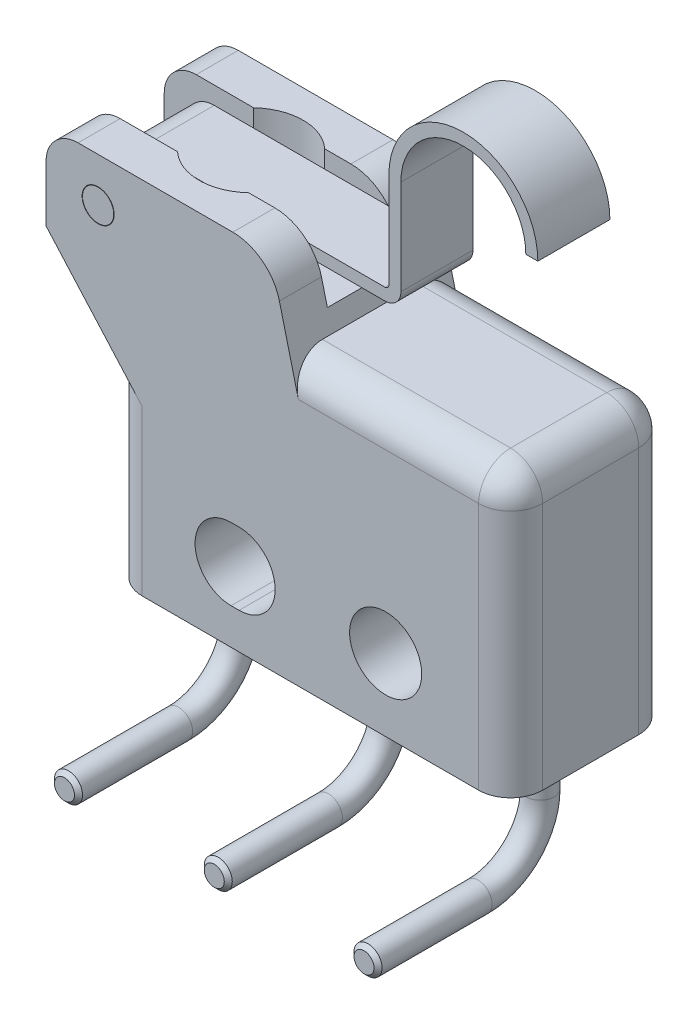
from build123d import *

# Parameters (mm, degrees)
BOSS_EXTRUDE3_DEPTH        = 5.08
SKETCH5_R                  = 1.143
SKETCH5_R_2                = 0.508
CUT_EXTRUDE1_DEPTH         = 6.08
CUT_EXTRUDE2_DEPTH         = 1.905
SKETCH7_W                  = 2.032
SKETCH7_H                  = 2.413
CUT_EXTRUDE3_DEPTH         = 10.525
SKETCH8_R                  = 0.4953
BOSS_EXTRUDE4_DEPTH        = 5.08
SKETCH9_R                  = 1.5875
BOSS_EXTRUDE5_DEPTH        = 0.254
SKETCH10_R                 = 0.7874
BOSS_EXTRUDE6_DEPTH        = 0.7112
BOSS_EXTRUDE7_DEPTH        = 2.286
SKETCH13_R                 = 0.4445
CHAMFER1_SIZE              = 0.127
LPATTERN1_COUNT            = 2
LPATTERN1_PITCH            = 4.7498
LPATTERN1_COUNT_DIR2       = 2
LPATTERN1_PITCH_DIR2       = 4.7498
CHAMFER1_OF_LPATTERN1_SIZE = 0.127
FILLET1_R                  = 1.016
FILLET2_R                  = 1.524
CUT_EXTRUDE4_DEPTH         = 0.0254
CUT_EXTRUDE5_DEPTH         = 0.0254
CUT_EXTRUDE6_DEPTH         = 0.0254


with BuildPart() as part:
    # Sketch4 → Boss-Extrude3 (new body)
    with BuildSketch(Plane.XY):
        Polygon((0, 0), (12.7, 0), (12.7, 8.89), (5.715, 8.89), (5.08, 11.43), (-2.032, 11.43), (-2.032, 8.636), (0, 6.35), align=None)
    extrude(amount=BOSS_EXTRUDE3_DEPTH)

    # Sketch5 → Cut-Extrude1 (cut, through all)
    with BuildSketch(Plane.XY.offset(5.08)):
        with Locations((8.7376, 2.286)):
            Circle(SKETCH5_R)
        with Locations((-0.381, 10.033)):
            Circle(SKETCH5_R_2)
        with BuildLine():
            Line((3.8354, 3.429), (4.0894, 3.429))
            ThreePointArc((4.0894, 3.429), (5.2324, 2.286), (4.0894, 1.143))
            Line((4.0894, 1.143), (3.8354, 1.143))
            ThreePointArc((3.8354, 1.143), (2.6924, 2.286), (3.8354, 3.429))
        make_face()
    extrude(amount=-CUT_EXTRUDE1_DEPTH, mode=Mode.SUBTRACT)

    # Sketch6 → Cut-Extrude2 (cut)
    with BuildSketch(Plane(origin=(0, 11.43, 0), x_dir=(1, 0, 0), z_dir=(0, 1, 0))):
        with BuildLine():
            Line((-2.032, -1.3335), (0.803386801, -1.3335))
            ThreePointArc((0.803386801, -1.3335), (1.9304, -0.889), (3.057413199, -1.3335))
            Line((3.057413199, -1.3335), (5.842, -1.3335))
            Line((5.842, -1.3335), (5.842, -3.7465))
            Line((5.842, -3.7465), (3.057413199, -3.7465))
            ThreePointArc((3.057413199, -3.7465), (1.9304, -4.191), (0.803386801, -3.7465))
            Line((0.803386801, -3.7465), (-2.032, -3.7465))
            Line((-2.032, -3.7465), (-2.032, -1.3335))
        make_face()
    extrude(amount=-CUT_EXTRUDE2_DEPTH, mode=Mode.SUBTRACT)

    # Sketch7 → Cut-Extrude3 (cut, through all)
    with BuildSketch(Plane(origin=(0, 9.525, 0), x_dir=(1, 0, 0), z_dir=(0, 1, 0))):
        with Locations((-1.016, -2.54)):
            Rectangle(SKETCH7_W, SKETCH7_H)
    extrude(amount=-CUT_EXTRUDE3_DEPTH, mode=Mode.SUBTRACT)

    # Sketch9 → Boss-Extrude5 (add)
    with BuildSketch(Plane(origin=(0, 9.525, 0), x_dir=(1, 0, 0), z_dir=(0, 1, 0))):
        with Locations((1.9304, -2.54)):
            Circle(SKETCH9_R)
    extrude(amount=BOSS_EXTRUDE5_DEPTH)

    # Sketch10 → Boss-Extrude6 (add)
    with BuildSketch(Plane(origin=(0, 9.779, 0), x_dir=(1, 0, 0), z_dir=(0, 1, 0))):
        with Locations((1.9304, -2.54)):
            Circle(SKETCH10_R)
    extrude(amount=BOSS_EXTRUDE6_DEPTH)

    # Sweep1: sweep along a path in Sketch15
    with BuildLine(Plane(origin=(6.35, 0, 0), x_dir=(0, 0, -1), z_dir=(1, 0, 0))) as sweep1_path:
        Line((-2.54, 0), (-2.54, -1.524))
        ThreePointArc((-2.54, -1.524), (-3.116560301, -2.915939699), (-4.5085, -3.4925))
        Line((-4.5085, -3.4925), (-8.128, -3.4925))
    # Sketch13 → Sweep1 (sweep)
    with BuildSketch(Plane.XZ):
        with Locations((6.35, 2.54)):
            Circle(SKETCH13_R)
    sweep1 = sweep(path=sweep1_path.line)

    # Chamfer1
    chamfer1_edges = [part.edges().sort_by_distance(p)[0] for p in [
        (5.9055, -3.4925, 8.128),
    ]]
    chamfer(chamfer1_edges, length=CHAMFER1_SIZE)

    # LPattern1: Sweep1 2 × 2
    with Locations(*[Vector(1, 0, 0) * (i * LPATTERN1_PITCH) + Vector(-1, 0, 0) * (j * LPATTERN1_PITCH_DIR2) for i in range(LPATTERN1_COUNT) for j in range(LPATTERN1_COUNT_DIR2) if (i, j) != (0, 0)]):
        add(sweep1)

    # Chamfer1 of LPattern1
    chamfer1_of_lpattern1_edges = [part.edges().sort_by_distance(p)[0] for p in [
        (1.1557, -3.4925, 8.128),
        (10.6553, -3.4925, 8.128),
        (5.9055, -3.4925, 8.128),
    ]]
    chamfer(chamfer1_of_lpattern1_edges, length=CHAMFER1_OF_LPATTERN1_SIZE)

    # Fillet1
    fillet1_edges = [part.edges().sort_by_distance(p)[0] for p in [
        (12.7, 4.445, 5.08),
        (0, 3.175, 0),
        (9.2075, 8.89, 5.08),
        (-2.032, 11.43, 4.41325),
        (12.7, 8.89, 2.54),
        (0, 3.175, 5.08),
        (-2.032, 11.43, 0.66675),
        (9.2075, 8.89, 0),
        (12.7, 4.445, 0),
    ]]
    fillet(fillet1_edges, radius=FILLET1_R)

    # Fillet2
    fillet2_edges = [part.edges().sort_by_distance(p)[0] for p in [
        (5.08, 11.43, 4.41325),
        (5.08, 11.43, 0.66675),
    ]]
    fillet(fillet2_edges, radius=FILLET2_R)

    # Sketch16 → Cut-Extrude4 (cut)
    with BuildSketch(Plane.XZ):
        with BuildLine():
            Line((1.939123423, 1.681786727), (2.018625627, 1.577903847))
            add(Edge.make_bspline(
                [(2.018625627, 1.577903847), (2.009793963, 1.570493212), (1.992249706, 1.555771854), (1.967611674, 1.532089284), (1.94453688, 1.507402641), (1.922877068, 1.481746274), (1.903502788, 1.454526435), (1.884905157, 1.426780277), (1.868622291, 1.397499658), (1.848730733, 1.357215763), (1.828426479, 1.304312077), (1.810963067, 1.237945187), (1.799951042, 1.168569238), (1.798750274, 1.121249335), (1.798139516, 1.097180523)],
                knots=[0, 0, 0, 0, 3.4579e-05, 6.8692e-05, 0.000102441, 0.00013593, 0.000169326, 0.000202622, 0.000236084, 0.000269743, 0.000337363, 0.000405629, 0.000475341, 0.000547505, 0.000547505, 0.000547505, 0.000547505], degree=3))
            add(Edge.make_bspline(
                [(1.798139516, 1.097180523), (1.798292204, 1.083919872), (1.798596163, 1.057521639), (1.80260616, 1.018344984), (1.808242242, 0.979899872), (1.816605088, 0.942211312), (1.827178071, 0.905327277), (1.839812083, 0.869006639), (1.855443223, 0.833775245), (1.872719875, 0.799145756), (1.892233756, 0.765967218), (1.913519093, 0.734574698), (1.936336334, 0.705080853), (1.960775997, 0.677469078), (1.986709644, 0.651686381), (2.014427817, 0.628057197), (2.0436342, 0.606265825), (2.074353049, 0.586436456), (2.106298263, 0.568585419), (2.139652232, 0.553575473), (2.173843867, 0.540465888), (2.209115563, 0.529929183), (2.245232887, 0.521653986), (2.282345462, 0.515932896), (2.320382924, 0.511969372), (2.346164376, 0.511666806), (2.359160065, 0.511514291)],
                knots=[0, 0, 0, 0, 3.9765e-05, 7.9161e-05, 0.000118027, 0.000156286, 0.000194871, 0.000233091, 0.000271543, 0.000310416, 0.00034914, 0.00038692, 0.000424131, 0.000460928, 0.00049747, 0.000533745, 0.000570104, 0.00060671, 0.000643364, 0.000679771, 0.00071634, 0.000753146, 0.000790111, 0.000827406, 0.000865747, 0.000904717, 0.000904717, 0.000904717, 0.000904717], degree=3))
            add(Edge.make_bspline(
                [(2.359160065, 0.511514291), (2.378712836, 0.511992347), (2.417102109, 0.512930946), (2.473340046, 0.521248816), (2.527267745, 0.533990163), (2.578520068, 0.552773327), (2.627524265, 0.576396137), (2.673686059, 0.605870889), (2.717681735, 0.640137018), (2.758445743, 0.679546049), (2.795681059, 0.722789867), (2.828470853, 0.769185352), (2.85580412, 0.818618779), (2.878549205, 0.870543853), (2.896033144, 0.925360277), (2.908341608, 0.982969442), (2.916370646, 1.04324606), (2.917139332, 1.084433898), (2.917530541, 1.105395751)],
                knots=[0, 0, 0, 0, 5.8627e-05, 0.000115105, 0.000170189, 0.000224596, 0.000278524, 0.000333076, 0.00038858, 0.000445557, 0.000502873, 0.000559559, 0.000615671, 0.000672044, 0.000729369, 0.00078795, 0.000848595, 0.000911447, 0.000911447, 0.000911447, 0.000911447], degree=3))
            add(Edge.make_bspline(
                [(2.917530541, 1.105395751), (2.916892223, 1.128491113), (2.915635859, 1.173948309), (2.904992333, 1.240611224), (2.887734728, 1.304427123), (2.863582834, 1.36539944), (2.832186133, 1.423356286), (2.794124733, 1.478388357), (2.749036584, 1.530542105), (2.71460933, 1.561903274), (2.69704443, 1.577903847)],
                knots=[0, 0, 0, 0, 6.9253e-05, 0.000136306, 0.000201943, 0.000267246, 0.000332579, 0.000399252, 0.000467635, 0.000538868, 0.000538868, 0.000538868, 0.000538868], degree=3))
            Line((2.69704443, 1.577903847), (2.775751612, 1.681786727))
            add(Edge.make_bspline(
                [(2.775751612, 1.681786727), (2.786538094, 1.673426315), (2.808059391, 1.656745536), (2.838405723, 1.629740455), (2.866923767, 1.601271188), (2.893471107, 1.571264557), (2.918157625, 1.539667673), (2.940996731, 1.506483437), (2.961867219, 1.471740175), (2.981037786, 1.435713847), (2.997916821, 1.398321438), (3.012874111, 1.359892131), (3.025257096, 1.320190298), (3.035731711, 1.279550142), (3.043200583, 1.237604624), (3.049148207, 1.194841329), (3.052676779, 1.150860009), (3.05303352, 1.121214092), (3.053214302, 1.106190773)],
                knots=[0, 0, 0, 0, 4.0932e-05, 8.1668e-05, 0.00012177, 0.000161758, 0.000201782, 0.00024199, 0.00028253, 0.000323311, 0.000364346, 0.000405538, 0.000446942, 0.000489041, 0.000531351, 0.000574677, 0.000618538, 0.000663602, 0.000663602, 0.000663602, 0.000663602], degree=3))
            add(Edge.make_bspline(
                [(3.053214302, 1.106190773), (3.053115275, 1.091962363), (3.052919461, 1.063827445), (3.049747422, 1.022288333), (3.045419694, 0.981848819), (3.038903335, 0.942624481), (3.031213659, 0.90440127), (3.020905773, 0.867525692), (3.009358916, 0.831634884), (2.995787685, 0.796873041), (2.980473533, 0.763210595), (2.963165414, 0.730756118), (2.944008876, 0.699524538), (2.923426179, 0.669208799), (2.900756186, 0.640256736), (2.876313738, 0.612417457), (2.850181216, 0.585534854), (2.831337269, 0.568902887), (2.82186289, 0.56054065)],
                knots=[0, 0, 0, 0, 4.2674e-05, 8.4382e-05, 0.000124914, 0.000164647, 0.000203628, 0.000241816, 0.000279444, 0.000316698, 0.000353697, 0.000390331, 0.000426963, 0.000463569, 0.000500199, 0.000537195, 0.000574675, 0.000612574, 0.000612574, 0.000612574, 0.000612574], degree=3))
            add(Edge.make_bspline(
                [(2.82186289, 0.56054065), (2.805405017, 0.547147694), (2.772687967, 0.520523473), (2.719668205, 0.486445248), (2.664360374, 0.457371731), (2.606444123, 0.433602313), (2.545896936, 0.415344628), (2.482816215, 0.402508288), (2.417328063, 0.394225018), (2.372789191, 0.393274271), (2.350149815, 0.392791)],
                knots=[0, 0, 0, 0, 6.3616e-05, 0.000126463, 0.000188695, 0.00025085, 0.000313978, 0.000378113, 0.000443788, 0.000511682, 0.000511682, 0.000511682, 0.000511682], degree=3))
            add(Edge.make_bspline(
                [(2.350149815, 0.392791), (2.326354153, 0.393378826), (2.279537672, 0.394535338), (2.210831446, 0.404361129), (2.145006364, 0.420167639), (2.082185306, 0.442618248), (2.022037848, 0.471081878), (1.965023464, 0.506243723), (1.910777531, 0.547695292), (1.860123146, 0.595111486), (1.813806188, 0.647108663), (1.77305801, 0.702791667), (1.739146925, 0.76205151), (1.710800162, 0.824235341), (1.689011927, 0.889808798), (1.673759383, 0.958631976), (1.664265711, 1.030575554), (1.663065558, 1.079660459), (1.662455755, 1.104600729)],
                knots=[0, 0, 0, 0, 7.1358e-05, 0.000140392, 0.000207753, 0.000274138, 0.000340163, 0.000407022, 0.000474707, 0.000544645, 0.00061485, 0.000683335, 0.000751245, 0.000819323, 0.000888041, 0.000958119, 0.001030533, 0.001105332, 0.001105332, 0.001105332, 0.001105332], degree=3))
            add(Edge.make_bspline(
                [(1.662455755, 1.104600729), (1.66263815, 1.119800792), (1.662999183, 1.149887786), (1.666514386, 1.194396208), (1.672386606, 1.237725621), (1.680337206, 1.279921595), (1.690349382, 1.321106122), (1.702827761, 1.361202151), (1.717684148, 1.400111499), (1.734649453, 1.437821524), (1.753726842, 1.474077664), (1.77469129, 1.508857156), (1.797436871, 1.542021346), (1.822196447, 1.573397858), (1.848764641, 1.603025083), (1.876830243, 1.631342512), (1.907113438, 1.657525853), (1.928433896, 1.673684965), (1.939123423, 1.681786727)],
                knots=[0, 0, 0, 0, 4.5594e-05, 9.0248e-05, 0.000133836, 0.000176715, 0.000219008, 0.000260918, 0.000302605, 0.000343881, 0.000384896, 0.000425436, 0.000465645, 0.00050546, 0.00054525, 0.000584976, 0.000624989, 0.000665222, 0.000665222, 0.000665222, 0.000665222], degree=3))
        make_face()
    extrude(amount=-CUT_EXTRUDE4_DEPTH, mode=Mode.SUBTRACT)

    # Sketch17 → Cut-Extrude5 (cut)
    with BuildSketch(Plane.XZ):
        Polygon((10.765601094, 0.569944606), (9.442684428, 0.569944606), (9.442684428, 0.594855296), (10.483898287, 1.46884952), (9.442684428, 1.46884952), (9.442684428, 1.587572811), (10.765601094, 1.587572811), (10.765601094, 1.560542062), (9.726772302, 0.688667897), (10.765601094, 0.688667897), align=None)
        with BuildLine():
            Line((11.042268763, 1.791098452), (11.121770966, 1.687215573))
            add(Edge.make_bspline(
                [(11.121770966, 1.687215573), (11.112939303, 1.679804938), (11.095395046, 1.665083579), (11.070757013, 1.641401009), (11.04768222, 1.616714366), (11.026022407, 1.591057999), (11.006648128, 1.56383816), (10.988050496, 1.536092002), (10.97176763, 1.506811383), (10.951876072, 1.466527489), (10.931571818, 1.413623802), (10.914108407, 1.347256913), (10.903096381, 1.277880964), (10.901895614, 1.230561061), (10.901284855, 1.206492249)],
                knots=[0, 0, 0, 0, 3.4579e-05, 6.8692e-05, 0.000102441, 0.00013593, 0.000169326, 0.000202622, 0.000236084, 0.000269743, 0.000337363, 0.000405629, 0.000475341, 0.000547505, 0.000547505, 0.000547505, 0.000547505], degree=3))
            add(Edge.make_bspline(
                [(10.901284855, 1.206492249), (10.901437543, 1.193231597), (10.901741503, 1.166833365), (10.905751499, 1.12765671), (10.911387582, 1.089211598), (10.919750427, 1.051523038), (10.930323411, 1.014639003), (10.942957423, 0.978318364), (10.958588563, 0.943086971), (10.975865214, 0.908457481), (10.995379095, 0.875278944), (11.016664432, 0.843886423), (11.039481673, 0.814392578), (11.063921336, 0.786780804), (11.089854983, 0.760998106), (11.117573156, 0.737368923), (11.14677954, 0.71557755), (11.177498388, 0.695748182), (11.209443603, 0.677897145), (11.242797571, 0.662887199), (11.276989206, 0.649777613), (11.312260903, 0.639240908), (11.348378226, 0.630965711), (11.385490801, 0.625244621), (11.423528264, 0.621281097), (11.449309715, 0.620978531), (11.462305405, 0.620826016)],
                knots=[0, 0, 0, 0, 3.9765e-05, 7.9161e-05, 0.000118027, 0.000156286, 0.000194871, 0.000233091, 0.000271543, 0.000310416, 0.00034914, 0.00038692, 0.000424131, 0.000460928, 0.00049747, 0.000533745, 0.000570104, 0.00060671, 0.000643364, 0.000679771, 0.00071634, 0.000753146, 0.000790111, 0.000827406, 0.000865747, 0.000904717, 0.000904717, 0.000904717, 0.000904717], degree=3))
            add(Edge.make_bspline(
                [(11.462305405, 0.620826016), (11.481858176, 0.621304072), (11.520247449, 0.622242671), (11.576485385, 0.630560541), (11.630413085, 0.643301888), (11.681665408, 0.662085053), (11.730669604, 0.685707862), (11.776831399, 0.715182614), (11.820827075, 0.749448743), (11.861591082, 0.788857775), (11.898826398, 0.832101593), (11.931616192, 0.878497078), (11.958949459, 0.927930505), (11.981694544, 0.979855579), (11.999178483, 1.034672002), (12.011486947, 1.092281167), (12.019515985, 1.152557785), (12.020284671, 1.193745624), (12.020675881, 1.214707477)],
                knots=[0, 0, 0, 0, 5.8627e-05, 0.000115105, 0.000170189, 0.000224596, 0.000278524, 0.000333076, 0.00038858, 0.000445557, 0.000502873, 0.000559559, 0.000615671, 0.000672044, 0.000729369, 0.00078795, 0.000848595, 0.000911447, 0.000911447, 0.000911447, 0.000911447], degree=3))
            add(Edge.make_bspline(
                [(12.020675881, 1.214707477), (12.020037562, 1.237802838), (12.018781199, 1.283260035), (12.008137673, 1.349922949), (11.990880067, 1.413738849), (11.966728174, 1.474711166), (11.935331473, 1.532668011), (11.897270073, 1.587700082), (11.852181923, 1.639853831), (11.817754669, 1.671215), (11.80018977, 1.687215573)],
                knots=[0, 0, 0, 0, 6.9253e-05, 0.000136306, 0.000201943, 0.000267246, 0.000332579, 0.000399252, 0.000467635, 0.000538868, 0.000538868, 0.000538868, 0.000538868], degree=3))
            Line((11.80018977, 1.687215573), (11.878896951, 1.791098452))
            add(Edge.make_bspline(
                [(11.878896951, 1.791098452), (11.889683433, 1.78273804), (11.911204731, 1.766057262), (11.941551062, 1.73905218), (11.970069107, 1.710582913), (11.996616446, 1.680576282), (12.021302964, 1.648979399), (12.04414207, 1.615795163), (12.065012558, 1.5810519), (12.084183125, 1.545025572), (12.10106216, 1.507633164), (12.116019451, 1.469203856), (12.128402435, 1.429502023), (12.13887705, 1.388861867), (12.146345922, 1.346916349), (12.152293547, 1.304153054), (12.155822118, 1.260171734), (12.15617886, 1.230525818), (12.156359641, 1.215502499)],
                knots=[0, 0, 0, 0, 4.0932e-05, 8.1668e-05, 0.00012177, 0.000161758, 0.000201782, 0.00024199, 0.00028253, 0.000323311, 0.000364346, 0.000405538, 0.000446942, 0.000489041, 0.000531351, 0.000574677, 0.000618538, 0.000663602, 0.000663602, 0.000663602, 0.000663602], degree=3))
            add(Edge.make_bspline(
                [(12.156359641, 1.215502499), (12.156260614, 1.201274089), (12.156064801, 1.17313917), (12.152892761, 1.131600059), (12.148565034, 1.091160544), (12.142048674, 1.051936207), (12.134358998, 1.013712996), (12.124051113, 0.976837418), (12.112504255, 0.940946609), (12.098933025, 0.906184766), (12.083618873, 0.87252232), (12.066310754, 0.840067844), (12.047154215, 0.808836264), (12.026571518, 0.778520524), (12.003901526, 0.749568461), (11.979459078, 0.721729182), (11.953326556, 0.69484658), (11.934482608, 0.678214613), (11.925008229, 0.669852375)],
                knots=[0, 0, 0, 0, 4.2674e-05, 8.4382e-05, 0.000124914, 0.000164647, 0.000203628, 0.000241816, 0.000279444, 0.000316698, 0.000353697, 0.000390331, 0.000426963, 0.000463569, 0.000500199, 0.000537195, 0.000574675, 0.000612574, 0.000612574, 0.000612574, 0.000612574], degree=3))
            add(Edge.make_bspline(
                [(11.925008229, 0.669852375), (11.908550357, 0.656459419), (11.875833306, 0.629835199), (11.822813544, 0.595756974), (11.767505714, 0.566683456), (11.709589462, 0.542914039), (11.649042275, 0.524656353), (11.585961555, 0.511820013), (11.520473403, 0.503536743), (11.47593453, 0.502585996), (11.453295155, 0.502102726)],
                knots=[0, 0, 0, 0, 6.3616e-05, 0.000126463, 0.000188695, 0.00025085, 0.000313978, 0.000378113, 0.000443788, 0.000511682, 0.000511682, 0.000511682, 0.000511682], degree=3))
            add(Edge.make_bspline(
                [(11.453295155, 0.502102726), (11.429499492, 0.502690552), (11.382683012, 0.503847063), (11.313976786, 0.513672855), (11.248151703, 0.529479364), (11.185330645, 0.551929974), (11.125183188, 0.580393603), (11.068168804, 0.615555449), (11.013922871, 0.657007017), (10.963268486, 0.704423211), (10.916951528, 0.756420388), (10.87620335, 0.812103392), (10.842292265, 0.871363235), (10.813945501, 0.933547066), (10.792157266, 0.999120523), (10.776904723, 1.067943701), (10.767411051, 1.139887279), (10.766210898, 1.188972184), (10.765601094, 1.213912454)],
                knots=[0, 0, 0, 0, 7.1358e-05, 0.000140392, 0.000207753, 0.000274138, 0.000340163, 0.000407022, 0.000474707, 0.000544645, 0.00061485, 0.000683335, 0.000751245, 0.000819323, 0.000888041, 0.000958119, 0.001030533, 0.001105332, 0.001105332, 0.001105332, 0.001105332], degree=3))
            add(Edge.make_bspline(
                [(10.765601094, 1.213912454), (10.76578349, 1.229112518), (10.766144523, 1.259199512), (10.769659726, 1.303707933), (10.775531945, 1.347037346), (10.783482545, 1.38923332), (10.793494721, 1.430417847), (10.8059731, 1.470513877), (10.820829487, 1.509423224), (10.837794792, 1.54713325), (10.856872181, 1.583389389), (10.87783663, 1.618168882), (10.900582211, 1.651333071), (10.925341787, 1.682709584), (10.951909981, 1.712336808), (10.979975583, 1.740654238), (11.010258778, 1.766837578), (11.031579236, 1.78299669), (11.042268763, 1.791098452)],
                knots=[0, 0, 0, 0, 4.5594e-05, 9.0248e-05, 0.000133836, 0.000176715, 0.000219008, 0.000260918, 0.000302605, 0.000343881, 0.000384896, 0.000425436, 0.000465645, 0.00050546, 0.00054525, 0.000584976, 0.000624989, 0.000665222, 0.000665222, 0.000665222, 0.000665222], degree=3))
        make_face()
    extrude(amount=-CUT_EXTRUDE5_DEPTH, mode=Mode.SUBTRACT)

    # Sketch18 → Cut-Extrude6 (cut)
    with BuildSketch(Plane.XZ):
        Polygon((6.318402977, 0.619854477), (4.99548631, 0.619854477), (4.99548631, 0.644765168), (6.036700169, 1.518759392), (4.99548631, 1.518759392), (4.99548631, 1.637482682), (6.318402977, 1.637482682), (6.318402977, 1.610451933), (5.279574184, 0.738577768), (6.318402977, 0.738577768), align=None)
        with BuildLine():
            add(Edge.make_bspline(
                [(6.318402977, 1.238911635), (6.319012972, 1.263410227), (6.320211053, 1.311527483), (6.329684946, 1.382179367), (6.345277982, 1.449831715), (6.367298678, 1.514523418), (6.395845743, 1.576008438), (6.430522252, 1.634460425), (6.471538941, 1.689704204), (6.518293518, 1.741359509), (6.569497411, 1.788481115), (6.624312149, 1.829830569), (6.682048567, 1.864712735), (6.742709676, 1.893267587), (6.806153848, 1.915685039), (6.872736658, 1.931150375), (6.942022006, 1.941030271), (6.989279214, 1.942185241), (7.013252236, 1.942771144)],
                knots=[0, 0, 0, 0, 7.3476e-05, 0.000144313, 0.000213417, 0.000281466, 0.000348931, 0.000416423, 0.000485008, 0.000554995, 0.000625142, 0.000693461, 0.000760634, 0.000827139, 0.000894273, 0.000962087, 0.001031909, 0.001103797, 0.001103797, 0.001103797, 0.001103797], degree=3))
            add(Edge.make_bspline(
                [(7.013252236, 1.942771144), (7.037048528, 1.942185044), (7.083953777, 1.941029773), (7.152801431, 1.931142359), (7.218975052, 1.915616032), (7.282327149, 1.893545146), (7.342865053, 1.864968382), (7.400645179, 1.830034864), (7.455606327, 1.788763887), (7.507162973, 1.741842383), (7.554325367, 1.690540947), (7.595924435, 1.635936877), (7.630821786, 1.578201999), (7.659695427, 1.517934616), (7.681645703, 1.454661489), (7.697626228, 1.388843058), (7.707408044, 1.320120723), (7.708570617, 1.273306463), (7.709161524, 1.249511929)],
                knots=[0, 0, 0, 0, 7.1358e-05, 0.000140655, 0.000208211, 0.000275008, 0.000341513, 0.000408685, 0.000477216, 0.000547381, 0.000617528, 0.000686007, 0.000752953, 0.000819571, 0.000886118, 0.000953478, 0.001022513, 0.001093871, 0.001093871, 0.001093871, 0.001093871], degree=3))
            add(Edge.make_bspline(
                [(7.709161524, 1.249511929), (7.708575893, 1.225539047), (7.707421457, 1.178282114), (7.69752551, 1.108909484), (7.682050672, 1.042280694), (7.659935498, 0.978586282), (7.631353985, 0.917790728), (7.596502925, 0.859775131), (7.555149631, 0.804772358), (7.508217622, 0.753238424), (7.457125994, 0.706086198), (7.402382094, 0.664977743), (7.345059942, 0.630118846), (7.285000461, 0.601633301), (7.222493993, 0.579081556), (7.157123586, 0.563696104), (7.089261928, 0.553741741), (7.043057023, 0.552594641), (7.019612412, 0.552012597)],
                knots=[0, 0, 0, 0, 7.1887e-05, 0.000141709, 0.000209781, 0.000276828, 0.000343573, 0.000410973, 0.000479504, 0.000549668, 0.000619816, 0.000687763, 0.00075471, 0.000820735, 0.000886871, 0.000953654, 0.001021901, 0.0010922, 0.0010922, 0.0010922, 0.0010922], degree=3))
            add(Edge.make_bspline(
                [(7.019612412, 0.552012597), (7.003876254, 0.552214676), (6.972602458, 0.552616286), (6.926161808, 0.557451241), (6.880468018, 0.564467122), (6.835651023, 0.574522012), (6.791820532, 0.587672434), (6.748674261, 0.603189123), (6.706649461, 0.62214079), (6.665547048, 0.643564726), (6.62600775, 0.667476183), (6.588633622, 0.693887552), (6.553111043, 0.721871159), (6.520360538, 0.752548989), (6.489429365, 0.784909967), (6.460792861, 0.819479056), (6.434192806, 0.856045321), (6.410221427, 0.894766102), (6.38854104, 0.934687295), (6.369936352, 0.975840125), (6.353968346, 1.017665674), (6.34102613, 1.060359842), (6.330808664, 1.103809253), (6.323851122, 1.148108737), (6.319003835, 1.193223002), (6.318604125, 1.223616566), (6.318402977, 1.238911635)],
                knots=[0, 0, 0, 0, 4.719e-05, 9.3785e-05, 0.000139924, 0.000185828, 0.000231442, 0.000277132, 0.000323278, 0.000369625, 0.000416119, 0.000461776, 0.000506846, 0.000551664, 0.000596277, 0.000641065, 0.000686229, 0.00073182, 0.000777589, 0.000822418, 0.000867207, 0.000911805, 0.00095616, 0.001000991, 0.001046267, 0.001092132, 0.001092132, 0.001092132, 0.001092132], degree=3))
        make_face()
        with BuildLine():
            add(Edge.make_bspline(
                [(6.454086738, 1.244741797), (6.454239243, 1.232187296), (6.454542795, 1.207198315), (6.458563174, 1.170051474), (6.464252199, 1.133381895), (6.472514657, 1.097260538), (6.483201787, 1.06161165), (6.49609131, 1.026419404), (6.51167023, 0.991804463), (6.529190619, 0.95781007), (6.549090977, 0.925221386), (6.570223215, 0.893959926), (6.593372507, 0.864838828), (6.618038217, 0.83745805), (6.644434404, 0.811885684), (6.672387721, 0.788133011), (6.702019074, 0.766219509), (6.733206517, 0.746408896), (6.765775925, 0.728778998), (6.799104709, 0.712994211), (6.833584554, 0.699909224), (6.869000293, 0.689543965), (6.905195859, 0.680746236), (6.942368457, 0.675227649), (6.980389941, 0.671167656), (7.006085609, 0.670880918), (7.019082397, 0.670735887)],
                knots=[0, 0, 0, 0, 3.7646e-05, 7.4932e-05, 0.000111965, 0.00014893, 0.00018599, 0.000223552, 0.000261276, 0.000299798, 0.000338202, 0.000375763, 0.000412929, 0.000449705, 0.00048625, 0.0005231, 0.000559672, 0.000596725, 0.000633843, 0.000670714, 0.000707283, 0.000744342, 0.000781367, 0.000818924, 0.000857001, 0.000895971, 0.000895971, 0.000895971, 0.000895971], degree=3))
            add(Edge.make_bspline(
                [(7.019082397, 0.670735887), (7.038193279, 0.671218857), (7.075790294, 0.672169009), (7.130893381, 0.680452717), (7.183901338, 0.693313994), (7.234498217, 0.711960415), (7.282909643, 0.735747604), (7.328947217, 0.764763146), (7.372597358, 0.799272761), (7.413535133, 0.838449598), (7.450885788, 0.881288435), (7.48371721, 0.926755174), (7.51134905, 0.974490098), (7.534448647, 1.024218074), (7.551850923, 1.076363673), (7.564258737, 1.130592556), (7.572300594, 1.186905922), (7.57308165, 1.225280218), (7.573477763, 1.244741797)],
                knots=[0, 0, 0, 0, 5.7303e-05, 0.000112733, 0.000166787, 0.000220696, 0.000274147, 0.000328334, 0.000383629, 0.000440798, 0.000498087, 0.000553908, 0.00060877, 0.000663316, 0.000718123, 0.000773343, 0.000830047, 0.000888398, 0.000888398, 0.000888398, 0.000888398], degree=3))
            add(Edge.make_bspline(
                [(7.573477763, 1.244741797), (7.573298179, 1.257823416), (7.572942009, 1.283768195), (7.569349611, 1.322357118), (7.563600301, 1.36025441), (7.555281592, 1.397390051), (7.545008068, 1.433812696), (7.532264821, 1.469412445), (7.516988723, 1.504177475), (7.499964016, 1.538278732), (7.480624408, 1.570952657), (7.459777053, 1.602024491), (7.437036221, 1.631095418), (7.412701782, 1.65846335), (7.386386737, 1.683856496), (7.358603303, 1.707541541), (7.32890906, 1.729076153), (7.297849353, 1.748819606), (7.265517397, 1.766664617), (7.232096984, 1.781992825), (7.19776736, 1.795083431), (7.162503303, 1.805635943), (7.126384135, 1.813909152), (7.089358162, 1.819608725), (7.051500357, 1.823595859), (7.025894786, 1.823896369), (7.012987229, 1.824047853)],
                knots=[0, 0, 0, 0, 3.9235e-05, 7.7816e-05, 0.000116158, 0.000154157, 0.000191906, 0.000229626, 0.000267486, 0.000305767, 0.000343899, 0.000381311, 0.000417942, 0.00045454, 0.000491086, 0.000527562, 0.000563977, 0.00060103, 0.000637916, 0.000674674, 0.000711244, 0.000748049, 0.000785015, 0.000822309, 0.000860386, 0.000899092, 0.000899092, 0.000899092, 0.000899092], degree=3))
            add(Edge.make_bspline(
                [(7.012987229, 1.824047853), (7.000167975, 1.823896242), (6.974738625, 1.823595493), (6.937144804, 1.819610689), (6.900385406, 1.813902912), (6.864604742, 1.805677126), (6.829793692, 1.795074837), (6.795984953, 1.782001648), (6.763052562, 1.766585781), (6.731077962, 1.748893366), (6.700395733, 1.729005914), (6.67106428, 1.707274178), (6.643631975, 1.683324633), (6.617430861, 1.657835281), (6.592985015, 1.630193304), (6.570388892, 1.600393877), (6.548624387, 1.569178967), (6.529362558, 1.535842672), (6.511485231, 1.501561831), (6.496233127, 1.466353484), (6.48313373, 1.430720458), (6.472482753, 1.394520286), (6.464283848, 1.357770078), (6.458558083, 1.320491207), (6.454544176, 1.282813796), (6.454239701, 1.257472735), (6.454086738, 1.244741797)],
                knots=[0, 0, 0, 0, 3.8441e-05, 7.6254e-05, 0.000113287, 0.000149994, 0.000186292, 0.000222366, 0.000258644, 0.000295298, 0.000331904, 0.000368264, 0.000404712, 0.000441067, 0.000477864, 0.000515285, 0.000553215, 0.000591938, 0.000630696, 0.000669147, 0.000706958, 0.000744525, 0.000782266, 0.000819823, 0.000857636, 0.000895812, 0.000895812, 0.000895812, 0.000895812], degree=3))
        make_face(mode=Mode.SUBTRACT)
    extrude(amount=-CUT_EXTRUDE6_DEPTH, mode=Mode.SUBTRACT)


with BuildPart() as body_2:
    # Sketch8 → Boss-Extrude4 (new body)
    with BuildSketch(Plane.XY.offset(5.08)):
        with Locations((-0.381, 10.033)):
            Circle(SKETCH8_R)
    extrude(amount=-BOSS_EXTRUDE4_DEPTH)


with BuildPart() as body_3:
    # Sketch11 → Boss-Extrude7 (new body)
    with BuildSketch(Plane.XY.offset(1.397)):
        with BuildLine():
            Line((-0.381, 10.5537), (7.3152, 10.5537))
            ThreePointArc((7.3152, 10.5537), (7.674410245, 10.702489755), (7.8232, 11.0617))
            Line((7.8232, 11.0617), (7.8232, 14.0716))
            ThreePointArc((7.8232, 14.0716), (9.8044, 16.0528), (11.7856, 14.0716))
            Line((11.7856, 14.0716), (12.1666, 14.0716))
            ThreePointArc((12.1666, 14.0716), (9.8044, 16.4338), (7.4422, 14.0716))
            Line((7.4422, 14.0716), (7.4422, 11.0617))
            ThreePointArc((7.4422, 11.0617), (7.405002561, 10.971897439), (7.3152, 10.9347))
            Line((7.3152, 10.9347), (-0.381, 10.9347))
            ThreePointArc((-0.381, 10.9347), (-1.276912529, 9.931001812), (-0.178312954, 9.154375591))
            Line((-0.178312954, 9.154375591), (-0.263955368, 9.525625341))
            ThreePointArc((-0.263955368, 9.525625341), (-0.898357939, 9.974099638), (-0.381, 10.5537))
        make_face()
    extrude(amount=BOSS_EXTRUDE7_DEPTH)


solid = Compound([part.part, body_2.part, body_3.part])
